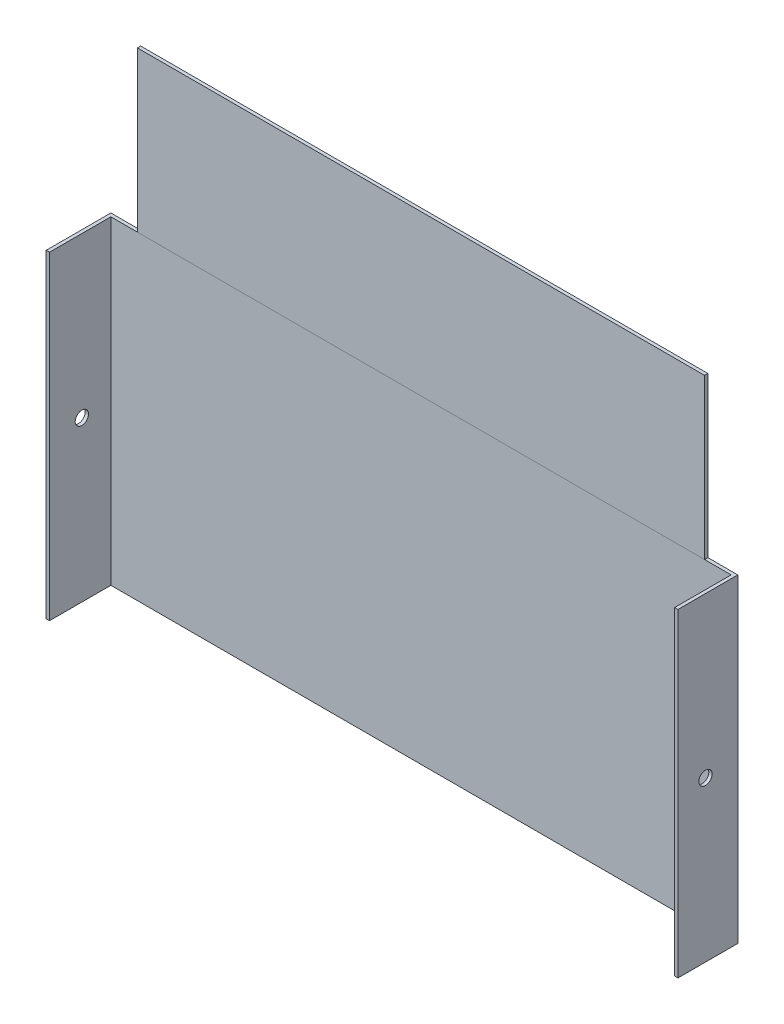
from build123d import *

# Parameters (mm, degrees)
BOSS_EXTRUDE1_DEPTH = 304.8
SKETCH4_R           = 6.35
CUT_EXTRUDE1_DEPTH  = 599.68125614
SKETCH5_W           = 541.53125614
SKETCH5_H           = 3.114661147
BOSS_EXTRUDE2_DEPTH = 152.4


with BuildPart() as part:
    # Sketch1 → Boss-Extrude1 (new body)
    with BuildSketch(Plane(origin=(0, 0, 0), x_dir=(1, 0, 0), z_dir=(0, 1, 0))):
        Polygon((595.50625614, 4.567872613), (3.175, 4.567872613), (3.175, -53.975), (0, -53.975), (0, 0), (0, 7.742872613), (598.68125614, 7.742872613), (598.68125614, 4.567872613), (598.68125614, -49.407127387), (595.50625614, -49.407127387), align=None)
    extrude(amount=BOSS_EXTRUDE1_DEPTH)

    # Sketch4 → Cut-Extrude1 (cut, through all)
    with BuildSketch(Plane.ZY):
        with Locations((23.116063694, 152.4)):
            Circle(SKETCH4_R)
    extrude(amount=-CUT_EXTRUDE1_DEPTH, mode=Mode.SUBTRACT)

    # Sketch5 → Boss-Extrude2 (add)
    with BuildSketch(Plane(origin=(0, 304.8, 0), x_dir=(1, 0, 0), z_dir=(0, 1, 0))):
        with Locations((299.34062807, 6.088586102)):
            Rectangle(SKETCH5_W, SKETCH5_H)
    extrude(amount=BOSS_EXTRUDE2_DEPTH)


solid = part.part
